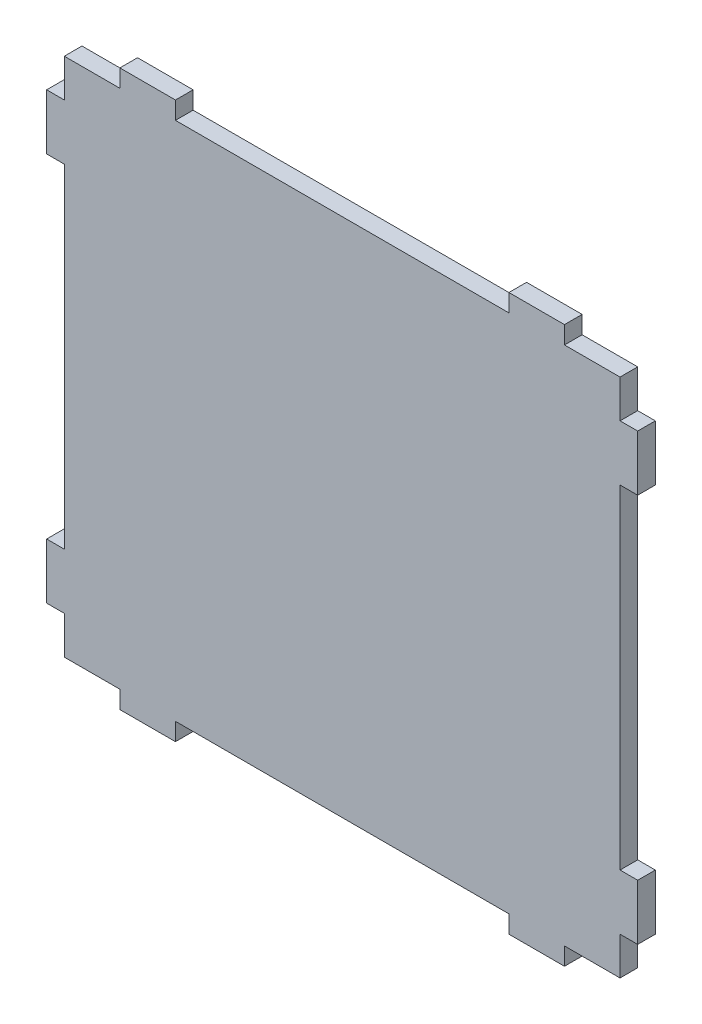
from build123d import *

# Parameters (mm, degrees)
BOSS_EXTRUDE1_DEPTH = 3.175


with BuildPart() as part:
    # Sketch1 → Boss-Extrude1 (new body)
    with BuildSketch(Plane.XY):
        Polygon((10, 3.175), (0, 3.175), (0, 10), (-3.175, 10), (-3.175, 20), (0, 20), (0, 80), (-3.175, 80), (-3.175, 90), (0, 90), (0, 96.825), (10, 96.825), (10, 100), (20, 100), (20, 96.825), (80, 96.825), (80, 100), (90, 100), (90, 96.825), (100, 96.825), (100, 90), (103.175, 90), (103.175, 80), (100, 80), (100, 20), (103.175, 20), (103.175, 10), (100, 10), (100, 3.175), (90, 3.175), (90, 0), (80, 0), (80, 3.175), (20, 3.175), (20, 0), (10, 0), align=None)
    extrude(amount=BOSS_EXTRUDE1_DEPTH)


solid = part.part
